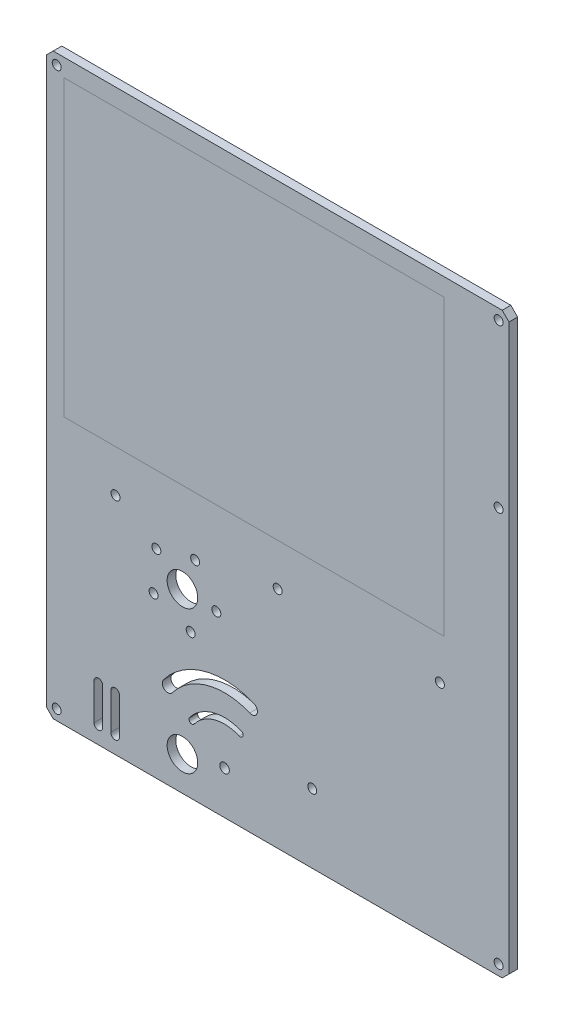
from build123d import *

# Parameters (mm, degrees)
SKETCH1_W           = 340
SKETCH1_H           = 425
BOSS_EXTRUDE1_DEPTH = 6.35
SKETCH3_R           = 11.25
CUT_EXTRUDE1_DEPTH  = 7.35
SKETCH5_R           = 3.522259684
CUT_EXTRUDE2_DEPTH  = 10
CUT_EXTRUDE3_DEPTH  = 17
SKETCH8_R           = 3.302
CUT_EXTRUDE4_DEPTH  = 7.35
SKETCH9_R           = 3.302
CUT_EXTRUDE5_DEPTH  = 7.35
CHAMFER1_SIZE       = 5


with BuildPart() as part:
    # Sketch1 → Boss-Extrude1 (new body)
    with BuildSketch(Plane.XY):
        with Locations((170, 212.5)):
            Rectangle(SKETCH1_W, SKETCH1_H)
    extrude(amount=BOSS_EXTRUDE1_DEPTH)

    # Sketch3 → Cut-Extrude1 (cut, through all)
    with BuildSketch(Plane.XY.offset(6.35)):
        with Locations((100, 130)):
            Circle(SKETCH3_R)
        with Locations((100, 25)):
            Circle(SKETCH3_R)
    extrude(amount=-CUT_EXTRUDE1_DEPTH, mode=Mode.SUBTRACT)

    # Sketch5 → Cut-Extrude2 (cut)
    with BuildSketch(Plane.XY.offset(6.35)):
        with Locations((130.96390727, 31.689171279)):
            Circle(SKETCH5_R)
        with BuildLine():
            ThreePointArc((108.598685831, 48.368705745), (123.600570447, 58.5999734), (141.721573091, 57.431794029))
            ThreePointArc((141.721573091, 57.431794029), (144.468906639, 58.559694013), (143.341006655, 61.307027562))
            ThreePointArc((143.341006655, 61.307027562), (122.49211114, 62.651061892), (105.231878303, 50.879603407))
            ThreePointArc((105.231878303, 50.879603407), (105.659833236, 47.940750812), (108.598685831, 48.368705745))
        make_face()
        with BuildLine():
            ThreePointArc((92.56626903, 60.325361276), (118.322192796, 77.890870979), (149.433161493, 75.885287041))
            ThreePointArc((149.433161493, 75.885287041), (154.797003183, 78.087377485), (152.594912738, 83.451219175))
            ThreePointArc((152.594912738, 83.451219175), (116.15805796, 85.800138986), (85.992978141, 65.227590044))
            ThreePointArc((85.992978141, 65.227590044), (86.828509201, 59.489830216), (92.56626903, 60.325361276))
        make_face()
    extrude(amount=-CUT_EXTRUDE2_DEPTH, mode=Mode.SUBTRACT)

    # Sketch6 → Cut-Extrude3 (cut)
    with BuildSketch(Plane.XY.offset(6.35)):
        with BuildLine():
            Line((41.389095845, 39.296844069), (41.389095845, 12.5))
            ThreePointArc((41.389095845, 12.5), (38.214095845, 9.325), (35.039095845, 12.5))
            Line((35.039095845, 12.5), (35.039095845, 39.296844069))
            ThreePointArc((35.039095845, 39.296844069), (38.214095845, 42.471844069), (41.389095845, 39.296844069))
        make_face()
        with BuildLine():
            Line((47.354853439, 39.296844069), (47.354853439, 12.5))
            ThreePointArc((47.354853439, 12.5), (50.529853439, 9.325), (53.704853439, 12.5))
            Line((53.704853439, 12.5), (53.704853439, 39.296844069))
            ThreePointArc((53.704853439, 39.296844069), (50.529853439, 42.471844069), (47.354853439, 39.296844069))
        make_face()
    extrude(amount=-CUT_EXTRUDE3_DEPTH, mode=Mode.SUBTRACT)

    # Sketch8 → Cut-Extrude4 (cut, through all)
    with BuildSketch(Plane.XY.offset(6.35)):
        with Locations((332.38, 417.38)):
            Circle(SKETCH8_R)
        with Locations((7.62, 417.38)):
            Circle(SKETCH8_R)
        with Locations((50.8, 165.1)):
            Circle(SKETCH8_R)
        with Locations((332.38, 7.62)):
            Circle(SKETCH8_R)
        with Locations((195.4, 50.8)):
            Circle(SKETCH8_R)
        with Locations((289.2, 165.1)):
            Circle(SKETCH8_R)
        with Locations((170, 165.1)):
            Circle(SKETCH8_R)
        with Locations((332.38, 298)):
            Circle(SKETCH8_R)
        with Locations((7.62, 7.62)):
            Circle(SKETCH8_R)
    extrude(amount=-CUT_EXTRUDE4_DEPTH, mode=Mode.SUBTRACT)

    # Sketch9 → Cut-Extrude5 (cut, through all)
    with BuildSketch(Plane.XY.offset(6.35)):
        with Locations((78.812282865, 116.730461854)):
            Circle(SKETCH9_R)
        with Locations((80.832554611, 146.050203652)):
            Circle(SKETCH9_R)
        with Locations((109.341584408, 153.189109529)):
            Circle(SKETCH9_R)
        with Locations((124.940862061, 128.281454206)):
            Circle(SKETCH9_R)
        with Locations((106.072716055, 105.748770759)):
            Circle(SKETCH9_R)
    extrude(amount=-CUT_EXTRUDE5_DEPTH, mode=Mode.SUBTRACT)

    # Chamfer1
    chamfer1_edges = [part.edges().sort_by_distance(p)[0] for p in [
        (0, 425, 3.175),
        (340, 425, 3.175),
        (340, 0, 3.175),
        (0, 0, 3.175),
    ]]
    chamfer(chamfer1_edges, length=CHAMFER1_SIZE)


solid = part.part
